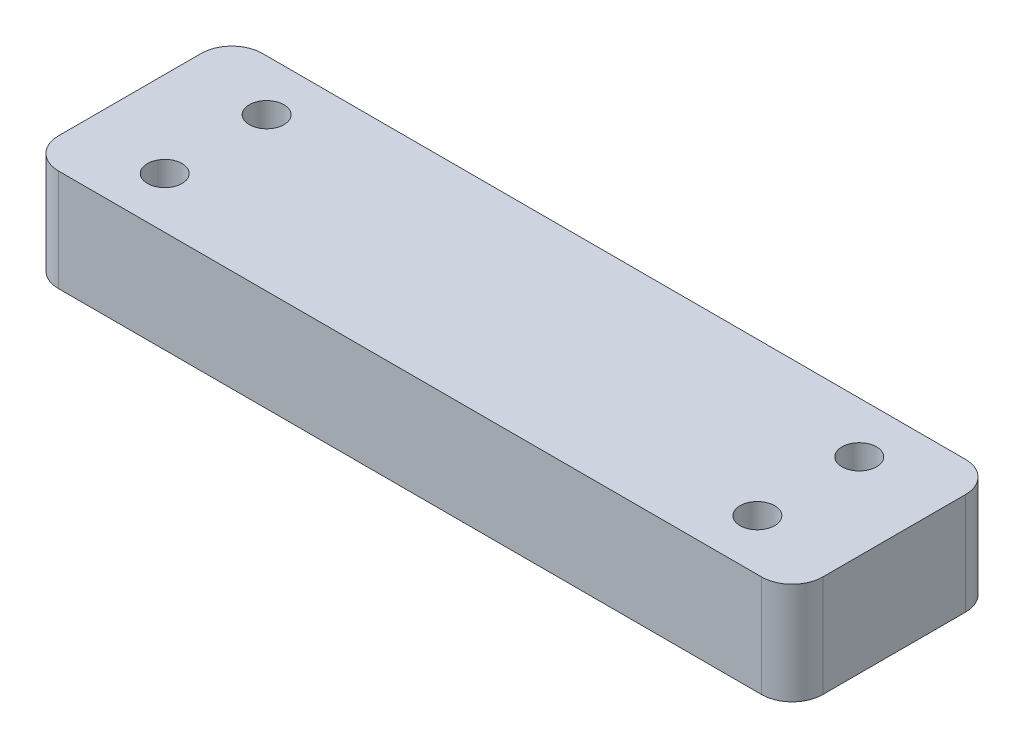
from build123d import *

# Parameters (mm, degrees)
SKETCH1_W            = 75
SKETCH1_H            = 20
BOSS_EXTRUDE1_DEPTH  = 10
FILLET1_R            = 3
M3_CLEARANCE_HOLE1_D = 3.4


with BuildPart() as part:
    # Sketch1 → Boss-Extrude1 (new body)
    with BuildSketch(Plane(origin=(0, 0, 0), x_dir=(1, 0, 0), z_dir=(0, 1, 0))):
        with Locations((37.5, 10)):
            Rectangle(SKETCH1_W, SKETCH1_H)
    extrude(amount=BOSS_EXTRUDE1_DEPTH)

    # Fillet1
    fillet1_edges = [part.edges().sort_by_distance(p)[0] for p in [
        (0, 5, -20),
        (75, 5, -20),
        (75, 5, 0),
        (0, 5, 0),
    ]]
    fillet(fillet1_edges, radius=FILLET1_R)

    # M3 Clearance Hole1 (through all)
    with Locations(Plane(origin=(67.535318197, 10, -35.416339767), x_dir=(1, 0, 0), z_dir=(0, 1, 0))):
        with Locations((-0.954318197, -20.416339767), (-0.954318197, -30.416339767), (-59.116318197, -30.416339767), (-59.116318197, -20.416339767)):
            Hole(M3_CLEARANCE_HOLE1_D / 2)


solid = part.part
